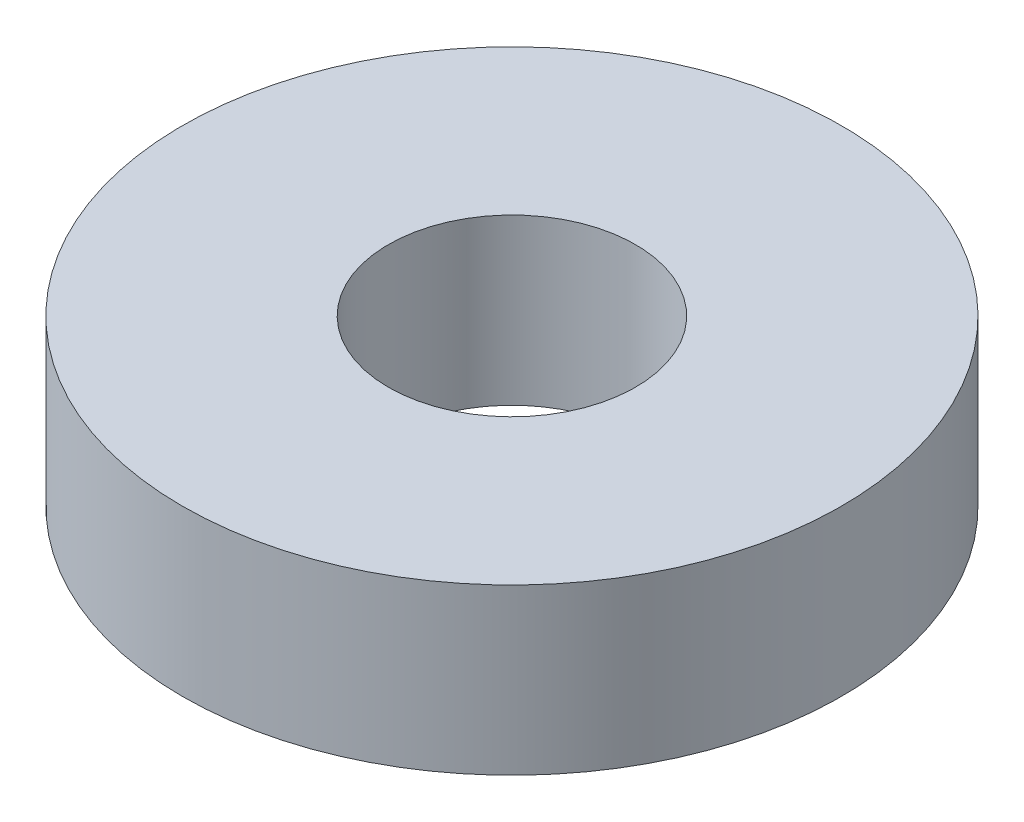
from build123d import *

# Parameters (mm, degrees)
SKETCH_1_R      = 20
SKETCH_1_R_2    = 7.5
EXTRUDE_1_DEPTH = 10


with BuildPart() as part:
    # 草图1 → 凸台-拉伸1 (new body)
    with BuildSketch(Plane(origin=(0, 0, 0), x_dir=(1, 0, 0), z_dir=(0, 1, 0))):
        Circle(SKETCH_1_R)
        Circle(SKETCH_1_R_2, mode=Mode.SUBTRACT)
    extrude(amount=EXTRUDE_1_DEPTH)


solid = part.part
